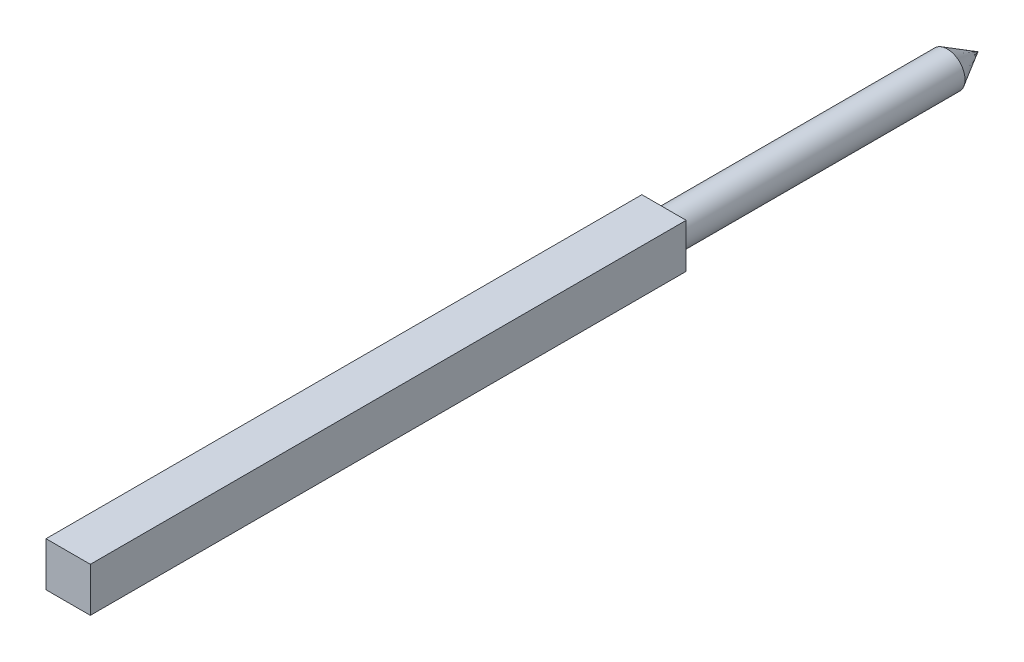
from build123d import *

# Parameters (mm, degrees)
SKETCH1_W           = 6.2611
SKETCH1_H           = 6.2484
BOSS_EXTRUDE1_DEPTH = 84.1375
SKETCH1_4_R         = 2.499995
BOSS_EXTRUDE2_DEPTH = 40.005


with BuildPart() as part:
    # Sketch1 → Boss-Extrude1 (new body)
    with BuildSketch(Plane.XY):
        Rectangle(SKETCH1_W, SKETCH1_H)
    extrude(amount=BOSS_EXTRUDE1_DEPTH)

    # Sketch1_4 → Boss-Extrude2 (add)
    with BuildSketch(Plane.XY):
        Circle(SKETCH1_4_R)
    extrude(amount=-BOSS_EXTRUDE2_DEPTH)

    # Boss-Extrude3 cone 1 section (through the dimple's axis) → Boss-Extrude3 (revolve)
    with BuildSketch(Plane(origin=(0, 0, -40.005), x_dir=(0, -1, 0), z_dir=(1, 0, 0))):
        Polygon((0, 0), (2.499995, 0), (0, 4.330118359), align=None)
    revolve(axis=Axis((0, 0, -40.005), (0, 0, -1)))


solid = part.part
